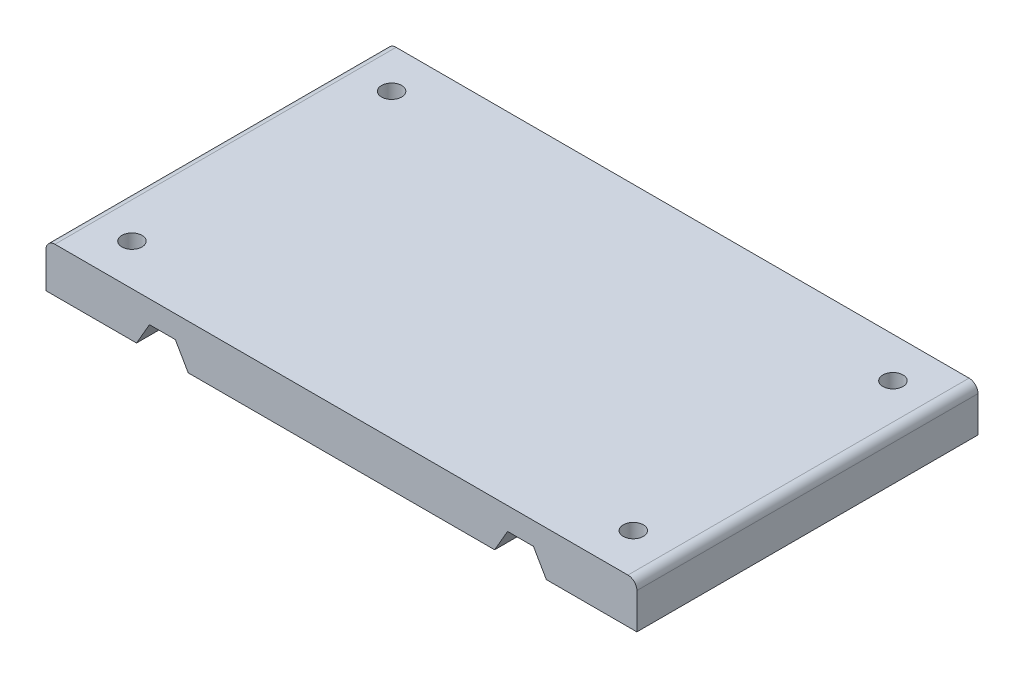
from build123d import *

# Parameters (mm, degrees)
SKETCH1_W            = 132
SKETCH1_H            = 10
BOSS_EXTRUDE1_DEPTH  = 76.2
CUT_EXTRUDE1_DEPTH   = 76.2
FILLET2_R            = 2
M4_CLEARANCE_HOLE1_D = 4.5


with BuildPart() as part:
    # Sketch1 → Boss-Extrude1 (new body)
    with BuildSketch(Plane.XY):
        with Locations((0, 5)):
            Rectangle(SKETCH1_W, SKETCH1_H)
    extrude(amount=BOSS_EXTRUDE1_DEPTH)

    # Sketch2 → Cut-Extrude1 (cut)
    with BuildSketch(Plane.XY.offset(76.2)):
        Polygon((34.226497308, 0), (37.113248654, -5), (42.886751346, -5), (45.773502692, 0), (42.886751346, 5), (37.113248654, 5), align=None)
        Polygon((-37.113248654, 5), (-34.226497308, 0), (-37.113248654, -5), (-42.886751346, -5), (-45.773502692, 0), (-42.886751346, 5), align=None)
    extrude(amount=-CUT_EXTRUDE1_DEPTH, mode=Mode.SUBTRACT)

    # Fillet2
    fillet2_edges = [part.edges().sort_by_distance(p)[0] for p in [
        (66, 10, 38.1),
        (-66, 10, 38.1),
    ]]
    fillet(fillet2_edges, radius=FILLET2_R)

    # M4 Clearance Hole1 (through all)
    with Locations(Plane(origin=(0, 10, 0), x_dir=(1, 0, 0), z_dir=(0, 1, 0))):
        with Locations((-56, -67), (-56, -9), (56, -9), (56, -67)):
            Hole(M4_CLEARANCE_HOLE1_D / 2)


solid = part.part
